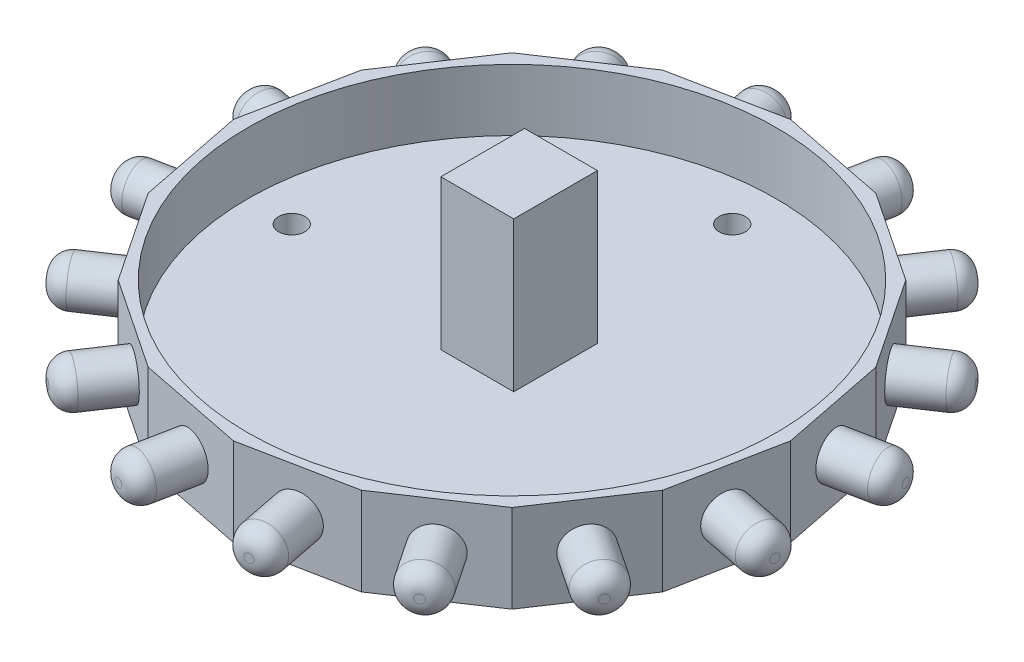
from build123d import *

# Parameters (mm, degrees)
ESQUISSE1_R                        = 1.5
EXTRUSION1_DEPTH                   = 10
ESQUISSE3_R                        = 30
EXTRUSION3_DEPTH                   = 7
ESQUISSE4_R                        = 2.5
EXTRUSION4_DEPTH                   = 7
CONG_1_R                           = 2
R_P_TITION_CIRCULAIRE1_COUNT       = 16
CONG_1_OF_R_P_TITION_CIRCULAIRE1_R = 2
ESQUISSE5_W                        = 8.27463906
ESQUISSE5_H                        = 9.500531968
EXTRUSION5_DEPTH                   = 17


with BuildPart() as part:
    # Esquisse1 → Extrusion1 (new body)
    with BuildSketch(Plane(origin=(0, 0, 0), x_dir=(1, 0, 0), z_dir=(0, 1, 0))):
        Polygon((0, 31.607325904), (-12.095599965, 29.201361481), (-22.349754482, 22.349754482), (-29.201361481, 12.095599965), (-31.607325904, 0), (-29.201361481, -12.095599965), (-22.349754482, -22.349754482), (-12.095599965, -29.201361481), (0, -31.607325904), (12.095599965, -29.201361481), (22.349754482, -22.349754482), (29.201361481, -12.095599965), (31.607325904, 0), (29.201361481, 12.095599965), (22.349754482, 22.349754482), (12.095599965, 29.201361481), align=None)
        with Locations((0, 25)):
            Circle(ESQUISSE1_R, mode=Mode.SUBTRACT)
        with Locations((-25, 0)):
            Circle(ESQUISSE1_R, mode=Mode.SUBTRACT)
        with Locations((0, -25)):
            Circle(ESQUISSE1_R, mode=Mode.SUBTRACT)
        with Locations((25, 0)):
            Circle(ESQUISSE1_R, mode=Mode.SUBTRACT)
    extrude(amount=EXTRUSION1_DEPTH)

    # Esquisse3 → Extrusion3 (cut)
    with BuildSketch(Plane(origin=(0, 10, 0), x_dir=(1, 0, 0), z_dir=(0, 1, 0))):
        Circle(ESQUISSE3_R)
    extrude(amount=-EXTRUSION3_DEPTH, mode=Mode.SUBTRACT)

    # Esquisse4 → Extrusion4 (add)
    with BuildSketch(Plane(origin=(6.047799983, 0, 30.404343693), x_dir=(0.98078528, 0, -0.195090322), z_dir=(0.195090322, 0, 0.98078528))):
        with Locations((0, 5)):
            Circle(ESQUISSE4_R)
    extrusion4 = extrude(amount=EXTRUSION4_DEPTH)

    # Congé1
    cong_1_edges = [part.edges().sort_by_distance(p)[0] for p in [
        (4.961469036, 5, 37.75756646),
    ]]
    fillet(cong_1_edges, radius=CONG_1_R)

    # Répétition circulaire1: Extrusion4 ×16 about axis
    r_p_tition_circulaire1_axis = Axis((0, 0, 0), (0, 1, 0))
    for i in range(1, R_P_TITION_CIRCULAIRE1_COUNT):
        add(extrusion4.rotate(r_p_tition_circulaire1_axis, i * 360 / R_P_TITION_CIRCULAIRE1_COUNT))

    # Congé1 of Répétition circulaire1
    cong_1_of_r_p_tition_circulaire1_edges = [part.edges().sort_by_distance(p)[0] for p in [
        (19.032994824, 5, 32.98477085),
        (30.206919685, 5, 23.190342886),
        (36.78211485, 5, 9.865395438),
        (37.75756646, 5, -4.961469036),
        (32.98477085, 5, -19.032994824),
        (23.190342886, 5, -30.206919685),
        (9.865395438, 5, -36.78211485),
        (-4.961469036, 5, -37.75756646),
        (-19.032994824, 5, -32.98477085),
        (-30.206919685, 5, -23.190342886),
        (-36.78211485, 5, -9.865395438),
        (-37.75756646, 5, 4.961469036),
        (-32.98477085, 5, 19.032994824),
        (-23.190342886, 5, 30.206919685),
        (-9.865395438, 5, 36.78211485),
    ]]
    fillet(cong_1_of_r_p_tition_circulaire1_edges, radius=CONG_1_OF_R_P_TITION_CIRCULAIRE1_R)

    # Esquisse5 → Extrusion5 (add)
    with BuildSketch(Plane(origin=(0, 3, 0), x_dir=(1, 0, 0), z_dir=(0, 1, 0))):
        with Locations((-0.061382832, 0.872037643)):
            Rectangle(ESQUISSE5_W, ESQUISSE5_H)
    extrude(amount=EXTRUSION5_DEPTH)


solid = part.part
